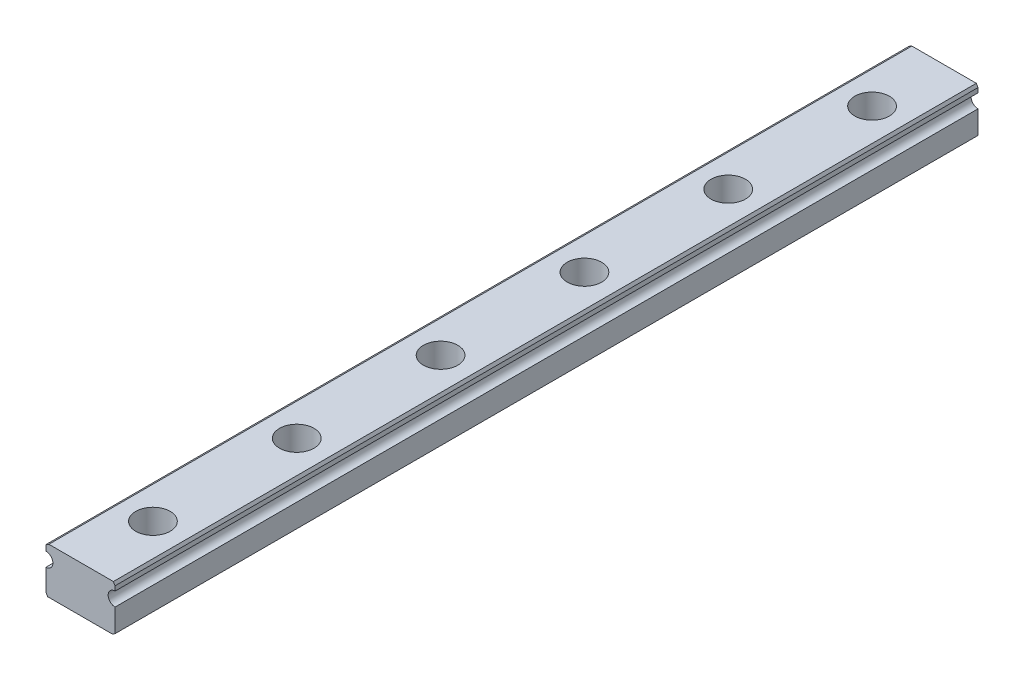
from build123d import *

# Parameters (mm, degrees)
BOSS_EXTRUDE1_DEPTH   = 75
CHAMFER1_SIZE         = 0.5
CHAMFER1_SIZE2        = 0.288675135
CHAMFER1_PART_2_SIZE  = 0.5
CHAMFER1_PART_2_SIZE2 = 0.288675135
CHAMFER1_PART_3_SIZE  = 0.5
CHAMFER1_PART_3_SIZE2 = 0.288675135
CHAMFER1_PART_4_SIZE  = 0.5
CHAMFER1_PART_4_SIZE2 = 0.288675135
SKETCH2_R             = 1.75
CUT_EXTRUDE1_DEPTH    = 8
SKETCH3_R             = 3
CUT_EXTRUDE2_DEPTH    = 4.5
LPATTERN1_COUNT       = 6
LPATTERN1_PITCH       = 25


with BuildPart() as part:
    # Sketch1 → Boss-Extrude1 (new body, symmetric)
    with BuildSketch(Plane.XY):
        with BuildLine():
            Line((-6, -4), (6, -4))
            Line((6, -4), (6, 0.3))
            ThreePointArc((6, 0.3), (4.8, 1.5), (6, 2.7))
            Line((6, 2.7), (6, 4))
            Line((6, 4), (-6, 4))
            Line((-6, 4), (-6, 2.7))
            ThreePointArc((-6, 2.7), (-4.8, 1.5), (-6, 0.3))
            Line((-6, 0.3), (-6, -4))
        make_face()
    extrude(amount=BOSS_EXTRUDE1_DEPTH, both=True)

    # Chamfer1
    chamfer1_edges = [part.edges().sort_by_distance(p)[0] for p in [
        (6, -4, 0),
    ]]
    chamfer1_side = [part.faces().sort_by_distance(p)[0] for p in [
        (0, -4, 0),
    ]]
    chamfer(chamfer1_edges, length=CHAMFER1_SIZE, length2=CHAMFER1_SIZE2, reference=chamfer1_side[0])

    # Chamfer1 part 2
    chamfer1_part_2_edges = [part.edges().sort_by_distance(p)[0] for p in [
        (-6, -4, 0),
    ]]
    chamfer1_part_2_side = [part.faces().sort_by_distance(p)[0] for p in [
        (-6, -1.85, 0),
    ]]
    chamfer(chamfer1_part_2_edges, length=CHAMFER1_PART_2_SIZE, length2=CHAMFER1_PART_2_SIZE2, reference=chamfer1_part_2_side[0])

    # Chamfer1 part 3
    chamfer1_part_3_edges = [part.edges().sort_by_distance(p)[0] for p in [
        (-6, 4, 0),
    ]]
    chamfer1_part_3_side = [part.faces().sort_by_distance(p)[0] for p in [
        (0, 4, 0),
    ]]
    chamfer(chamfer1_part_3_edges, length=CHAMFER1_PART_3_SIZE, length2=CHAMFER1_PART_3_SIZE2, reference=chamfer1_part_3_side[0])

    # Chamfer1 part 4
    chamfer1_part_4_edges = [part.edges().sort_by_distance(p)[0] for p in [
        (6, 4, 0),
    ]]
    chamfer1_part_4_side = [part.faces().sort_by_distance(p)[0] for p in [
        (6, 3.35, 0),
    ]]
    chamfer(chamfer1_part_4_edges, length=CHAMFER1_PART_4_SIZE, length2=CHAMFER1_PART_4_SIZE2, reference=chamfer1_part_4_side[0])

    # Sketch2 → Cut-Extrude1 (cut)
    with BuildSketch(Plane(origin=(0, 4, 0), x_dir=(1, 0, 0), z_dir=(0, 1, 0))):
        with Locations((0.088052027, -62.5)):
            Circle(SKETCH2_R)
    cut_extrude1 = extrude(amount=-CUT_EXTRUDE1_DEPTH, mode=Mode.SUBTRACT)

    # Sketch3 → Cut-Extrude2 (cut)
    with BuildSketch(Plane(origin=(0, 4, 0), x_dir=(1, 0, 0), z_dir=(0, 1, 0))):
        with Locations((0.088052027, -62.5)):
            Circle(SKETCH3_R)
    cut_extrude2 = extrude(amount=-CUT_EXTRUDE2_DEPTH, mode=Mode.SUBTRACT)

    # LPattern1: Cut-Extrude1, Cut-Extrude2 ×6
    with Locations(*[(0, 0, -i * LPATTERN1_PITCH) for i in range(1, LPATTERN1_COUNT)]):
        add(cut_extrude1, mode=Mode.SUBTRACT)
        add(cut_extrude2, mode=Mode.SUBTRACT)


solid = part.part
